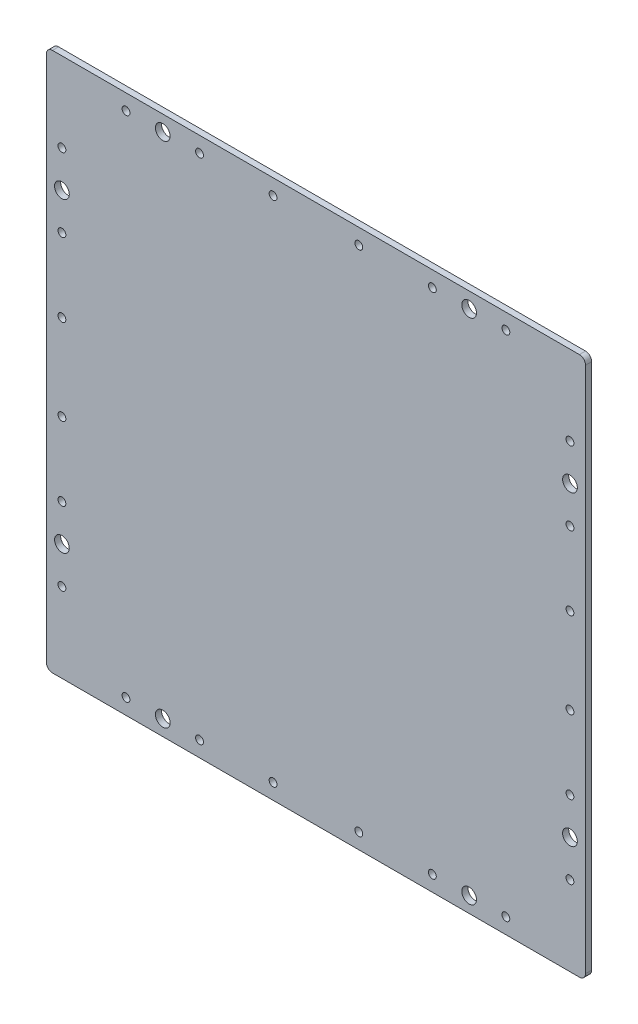
from build123d import *

# Parameters (mm, degrees)
SKETCH1_W           = 440
SKETCH1_H           = 440
BOSS_EXTRUDE1_DEPTH = 5
FILLET1_R           = 5
SKETCH2_R           = 3.2
CUT_EXTRUDE1_DEPTH  = 312.16715765
CIRPATTERN1_COUNT   = 4
CUT_EXTRUDE2_REACH  = 313.167
SKETCH3_R           = 6
CIRPATTERN2_COUNT   = 4


with BuildPart() as part:
    # Sketch1 → Boss-Extrude1 (new body)
    with BuildSketch(Plane.XY):
        Rectangle(SKETCH1_W, SKETCH1_H)
    extrude(amount=BOSS_EXTRUDE1_DEPTH)

    # Fillet1
    fillet1_edges = [part.edges().sort_by_distance(p)[0] for p in [
        (-220, -220, 2.5),
        (220, -220, 2.5),
        (220, 220, 2.5),
        (-220, 220, 2.5),
    ]]
    fillet(fillet1_edges, radius=FILLET1_R)

    # Sketch2 → Cut-Extrude1 (cut, through all)
    with BuildSketch(Plane(origin=(0, 0, 0), x_dir=(-1, 0, 0), z_dir=(0, 0, -1))):
        with Locations((-207.3, -155)):
            Circle(SKETCH2_R)
        with Locations((-207.3, -95)):
            Circle(SKETCH2_R)
        with Locations((-207.3, -35)):
            Circle(SKETCH2_R)
        with Locations((-207.3, 35)):
            Circle(SKETCH2_R)
        with Locations((-207.3, 95)):
            Circle(SKETCH2_R)
        with Locations((-207.3, 155)):
            Circle(SKETCH2_R)
    cut_extrude1 = extrude(amount=-CUT_EXTRUDE1_DEPTH, mode=Mode.SUBTRACT)

    # CirPattern1: Cut-Extrude1 ×4 about axis
    cirpattern1_axis = Axis((0, 0, -0.25), (0, 0, 1))
    for i in range(1, CIRPATTERN1_COUNT):
        add(cut_extrude1.rotate(cirpattern1_axis, i * 360 / CIRPATTERN1_COUNT), mode=Mode.SUBTRACT)

    # Sketch3 → Cut-Extrude2 (cut, up to next)
    with BuildSketch(Plane(origin=(0, 0, 0), x_dir=(-1, 0, 0), z_dir=(0, 0, -1)), mode=Mode.PRIVATE) as cut_extrude2_sk1:
        with Locations((207.3, -125)):
            Circle(SKETCH3_R)
    cut_extrude2_tool1 = extrude(cut_extrude2_sk1.sketch, amount=-CUT_EXTRUDE2_REACH, mode=Mode.PRIVATE) & part.part
    # Sketch3 → Cut-Extrude2 (cut, up to next)
    with BuildSketch(Plane(origin=(0, 0, 0), x_dir=(-1, 0, 0), z_dir=(0, 0, -1)), mode=Mode.PRIVATE) as cut_extrude2_sk2:
        with Locations((207.3, 125)):
            Circle(SKETCH3_R)
    cut_extrude2_tool2 = extrude(cut_extrude2_sk2.sketch, amount=-CUT_EXTRUDE2_REACH, mode=Mode.PRIVATE) & part.part
    cut_extrude2_1 = cut_extrude2_tool1.solids().sort_by_distance((-207.3, -125, 0))[0]
    add(cut_extrude2_1, mode=Mode.SUBTRACT)
    cut_extrude2_2 = cut_extrude2_tool2.solids().sort_by_distance((-207.3, 125, 0))[0]
    add(cut_extrude2_2, mode=Mode.SUBTRACT)
    cut_extrude2 = cut_extrude2_1 + cut_extrude2_2  # Cut-Extrude2 as one shape, for the pattern or mirror that repeats it

    # CirPattern2: Cut-Extrude2 ×4 about axis
    cirpattern2_axis = Axis((0, 0, -0.25), (0, 0, 1))
    for i in range(1, CIRPATTERN2_COUNT):
        add(cut_extrude2.rotate(cirpattern2_axis, i * 360 / CIRPATTERN2_COUNT), mode=Mode.SUBTRACT)


solid = part.part
